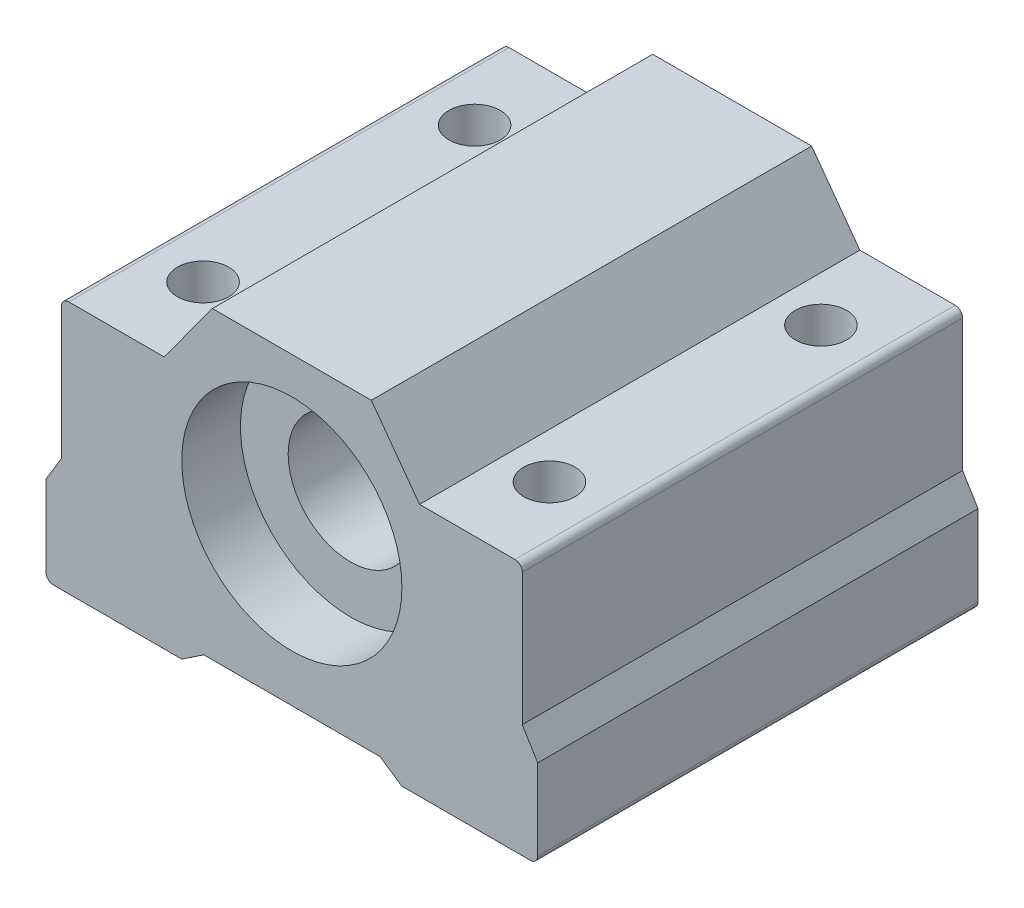
from build123d import *

# Parameters (mm, degrees)
SALIENTE_EXTRUIR1_DEPTH    = 30
CROQUIS2_R                 = 7.5
CORTAR_EXTRUIR1_DEPTH      = 4
CROQUIS3_R                 = 4.25
CORTAR_EXTRUIR2_DEPTH      = 16
CORTAR_EXTRUIR2_DEPTH_BACK = 16
CROQUIS5_R                 = 1.75
CORTAR_EXTRUIR3_DEPTH      = 1
CORTAR_EXTRUIR3_DEPTH_BACK = 22.73
CHAFL_N1_SIZE              = 0.5


with BuildPart() as part:
    # Croquis1 → Saliente-Extruir1 (new body)
    with BuildSketch(Plane.XY):
        with BuildLine():
            Line((-15.2, 0), (-8.7, 0))
            Line((-8.7, 0), (-5.415, 4.5))
            Line((-5.415, 4.5), (5.415, 4.5))
            Line((5.415, 4.5), (8.7, 0))
            Line((8.7, 0), (15.2, 0))
            ThreePointArc((15.2, 0), (15.553553391, -0.146446609), (15.7, -0.5))
            Line((15.7, -0.5), (15.7, -9.5))
            Line((15.7, -9.5), (16.75, -11.23))
            Line((16.75, -11.23), (16.75, -16.73))
            ThreePointArc((16.75, -16.73), (16.603553391, -17.083553391), (16.25, -17.23))
            Line((16.25, -17.23), (7.5, -17.23))
            Line((7.5, -17.23), (6, -16.23))
            Line((6, -16.23), (-6, -16.23))
            Line((-6, -16.23), (-7.5, -17.23))
            Line((-7.5, -17.23), (-16.25, -17.23))
            ThreePointArc((-16.25, -17.23), (-16.603553391, -17.083553391), (-16.75, -16.73))
            Line((-16.75, -16.73), (-16.75, -11.23))
            Line((-16.75, -11.23), (-15.7, -9.5))
            Line((-15.7, -9.5), (-15.7, -0.5))
            ThreePointArc((-15.7, -0.5), (-15.553553391, -0.146446609), (-15.2, 0))
        make_face()
    extrude(amount=SALIENTE_EXTRUIR1_DEPTH)

    # Croquis2 → Cortar-Extruir1 (cut)
    with BuildSketch(Plane.XY):
        with Locations((0, -5.5)):
            Circle(CROQUIS2_R)
    cortar_extruir1 = extrude(amount=CORTAR_EXTRUIR1_DEPTH, mode=Mode.SUBTRACT)

    # Simetría1: Cortar-Extruir1 across plane
    add(cortar_extruir1.mirror(Plane(origin=(0, 0, 15), x_dir=(1, 0, 0), z_dir=(0, 0, -1))), mode=Mode.SUBTRACT)

    # Croquis3 → Cortar-Extruir2 (cut, two sides)
    with BuildSketch(Plane(origin=(0, 0, 15), x_dir=(-1, 0, 0), z_dir=(0, 0, -1))) as cortar_extruir2_sk:
        with Locations((0, -5.5)):
            Circle(CROQUIS3_R)
    extrude(amount=CORTAR_EXTRUIR2_DEPTH, mode=Mode.SUBTRACT)
    extrude(cortar_extruir2_sk.sketch, amount=-CORTAR_EXTRUIR2_DEPTH_BACK, mode=Mode.SUBTRACT)

    # Croquis5 → Cortar-Extruir3 (cut, two sides)
    with BuildSketch(Plane.XZ.offset(17.23)) as cortar_extruir3_sk:
        with Locations((-11.8, 24.25)):
            Circle(CROQUIS5_R)
        with Locations((11.8, 24.25)):
            Circle(CROQUIS5_R)
        with Locations((11.8, 5.75)):
            Circle(CROQUIS5_R)
        with Locations((-11.8, 5.75)):
            Circle(CROQUIS5_R)
    extrude(amount=CORTAR_EXTRUIR3_DEPTH, mode=Mode.SUBTRACT)
    extrude(cortar_extruir3_sk.sketch, amount=-CORTAR_EXTRUIR3_DEPTH_BACK, mode=Mode.SUBTRACT)

    # Chaflán1
    chafl_n1_edges = [part.edges().sort_by_distance(p)[0] for p in [
        (-13.55, -17.23, 5.75),
        (10.05, -17.23, 5.75),
        (10.05, -17.23, 24.25),
        (-13.55, -17.23, 24.25),
    ]]
    chamfer(chafl_n1_edges, length=CHAFL_N1_SIZE)


solid = part.part
